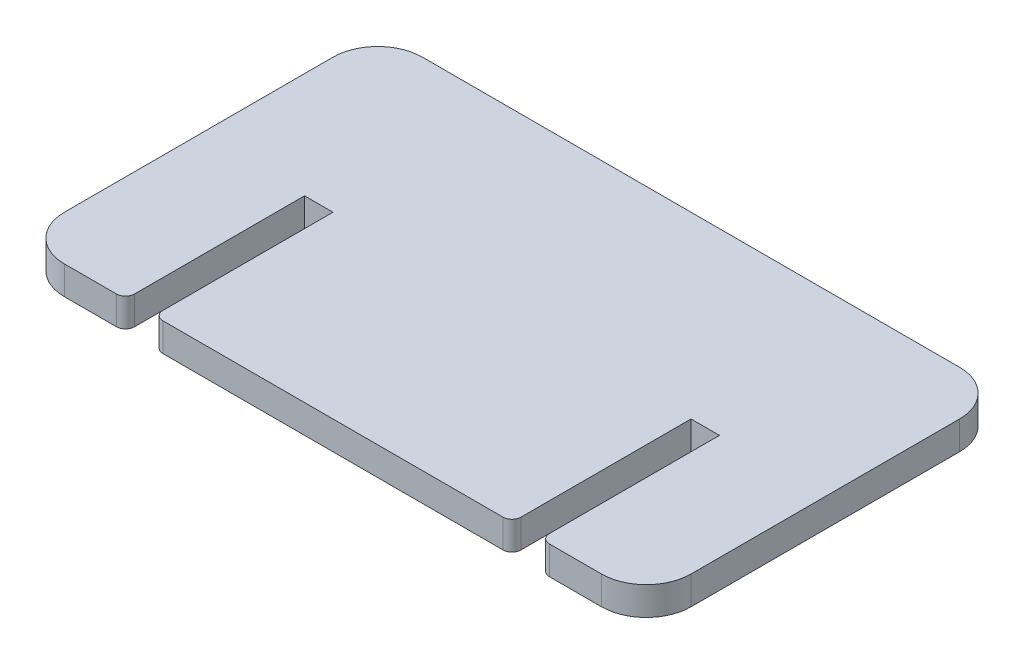
from build123d import *

# Parameters (mm, degrees)
BOSS_EXTRUDE1_DEPTH = 3.175
SKETCH2_W           = 3.175
SKETCH2_H           = 20
CUT_EXTRUDE1_DEPTH  = 4.175
FILLET1_R           = 1


with BuildPart() as part:
    # Sketch1 → Boss-Extrude1 (new body)
    with BuildSketch(Plane(origin=(0, 0, 0), x_dir=(1, 0, 0), z_dir=(0, 1, 0))):
        with BuildLine():
            Line((5, 0), (65, 0))
            ThreePointArc((65, 0), (68.535533906, 1.464466094), (70, 5))
            Line((70, 5), (70, 35))
            ThreePointArc((70, 35), (68.535533906, 38.535533906), (65, 40))
            Line((65, 40), (5, 40))
            ThreePointArc((5, 40), (1.464466094, 38.535533906), (0, 35))
            Line((0, 35), (0, 5))
            ThreePointArc((0, 5), (1.464466094, 1.464466094), (5, 0))
        make_face()
    extrude(amount=BOSS_EXTRUDE1_DEPTH)

    # Sketch2 → Cut-Extrude1 (cut, through all)
    with BuildSketch(Plane(origin=(0, 3.175, 0), x_dir=(1, 0, 0), z_dir=(0, 1, 0))):
        with Locations((13.4125, 10)):
            Rectangle(SKETCH2_W, SKETCH2_H)
        with Locations((56.5875, 10)):
            Rectangle(SKETCH2_W, SKETCH2_H)
    extrude(amount=-CUT_EXTRUDE1_DEPTH, mode=Mode.SUBTRACT)

    # Fillet1
    fillet1_edges = [part.edges().sort_by_distance(p)[0] for p in [
        (15, 1.5875, 0),
        (58.175, 1.5875, 0),
        (55, 1.5875, 0),
        (11.825, 1.5875, 0),
    ]]
    fillet(fillet1_edges, radius=FILLET1_R)


solid = part.part
